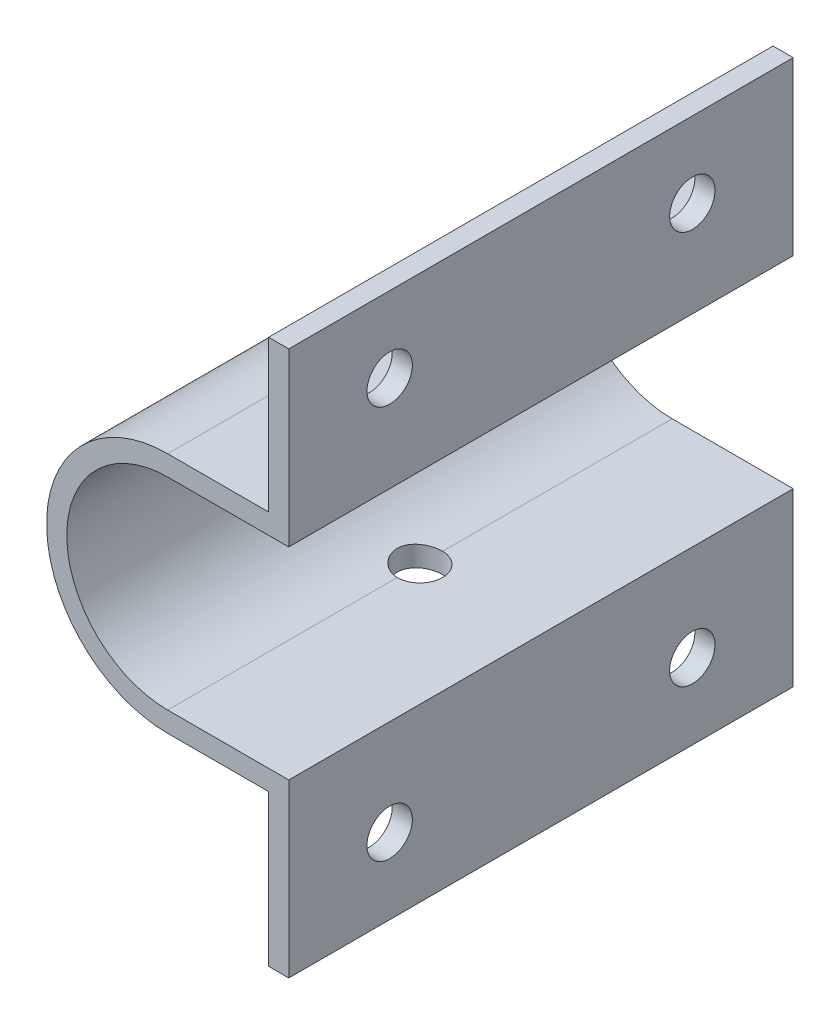
from build123d import *

# Parameters (mm, degrees)
BOSS_EXTRUDE1_DEPTH = 50
SKETCH2_R           = 2.25
CUT_EXTRUDE1_DEPTH  = 24
CUT_EXTRUDE2_REACH  = 4
SKETCH3_R           = 2.25


with BuildPart() as part:
    # Sketch1 → Boss-Extrude1 (new body)
    with BuildSketch(Plane.XY):
        with BuildLine():
            Line((0, 12), (10, 12))
            Line((10, 12), (10, 27))
            Line((10, 27), (12, 27))
            Line((12, 27), (12, 10))
            Line((12, 10), (0, 10))
            ThreePointArc((0, 10), (-10, 0), (0, -10))
            Line((0, -10), (12, -10))
            Line((12, -10), (12, -27))
            Line((12, -27), (10, -27))
            Line((10, -27), (10, -12))
            Line((10, -12), (0, -12))
            ThreePointArc((0, -12), (-12, 0), (0, 12))
        make_face()
    extrude(amount=BOSS_EXTRUDE1_DEPTH)

    # Sketch2 → Cut-Extrude1 (cut)
    with BuildSketch(Plane(origin=(0, 12, 0), x_dir=(1, 0, 0), z_dir=(0, 1, 0))):
        with Locations((0, -25)):
            Circle(SKETCH2_R)
    extrude(amount=-CUT_EXTRUDE1_DEPTH, mode=Mode.SUBTRACT)

    # Sketch3 → Cut-Extrude2 (cut, up to next)
    with BuildSketch(Plane.ZY.offset(-10), mode=Mode.PRIVATE) as cut_extrude2_sk1:
        with Locations((10, 19.5)):
            Circle(SKETCH3_R)
    cut_extrude2_tool1 = extrude(cut_extrude2_sk1.sketch, amount=-CUT_EXTRUDE2_REACH, mode=Mode.PRIVATE) & part.part
    add(cut_extrude2_tool1.solids().sort_by_distance((10, 19.5, 10))[0], mode=Mode.SUBTRACT)
    # Sketch3 → Cut-Extrude2 (cut, up to next)
    with BuildSketch(Plane.ZY.offset(-10), mode=Mode.PRIVATE) as cut_extrude2_sk2:
        with Locations((40, 19.5)):
            Circle(SKETCH3_R)
    cut_extrude2_tool2 = extrude(cut_extrude2_sk2.sketch, amount=-CUT_EXTRUDE2_REACH, mode=Mode.PRIVATE) & part.part
    add(cut_extrude2_tool2.solids().sort_by_distance((10, 19.5, 40))[0], mode=Mode.SUBTRACT)
    # Sketch3 → Cut-Extrude2 (cut, up to next)
    with BuildSketch(Plane.ZY.offset(-10), mode=Mode.PRIVATE) as cut_extrude2_sk3:
        with Locations((40, -19.5)):
            Circle(SKETCH3_R)
    cut_extrude2_tool3 = extrude(cut_extrude2_sk3.sketch, amount=-CUT_EXTRUDE2_REACH, mode=Mode.PRIVATE) & part.part
    add(cut_extrude2_tool3.solids().sort_by_distance((10, -19.5, 40))[0], mode=Mode.SUBTRACT)
    # Sketch3 → Cut-Extrude2 (cut, up to next)
    with BuildSketch(Plane.ZY.offset(-10), mode=Mode.PRIVATE) as cut_extrude2_sk4:
        with Locations((10, -19.5)):
            Circle(SKETCH3_R)
    cut_extrude2_tool4 = extrude(cut_extrude2_sk4.sketch, amount=-CUT_EXTRUDE2_REACH, mode=Mode.PRIVATE) & part.part
    add(cut_extrude2_tool4.solids().sort_by_distance((10, -19.5, 10))[0], mode=Mode.SUBTRACT)


solid = part.part
